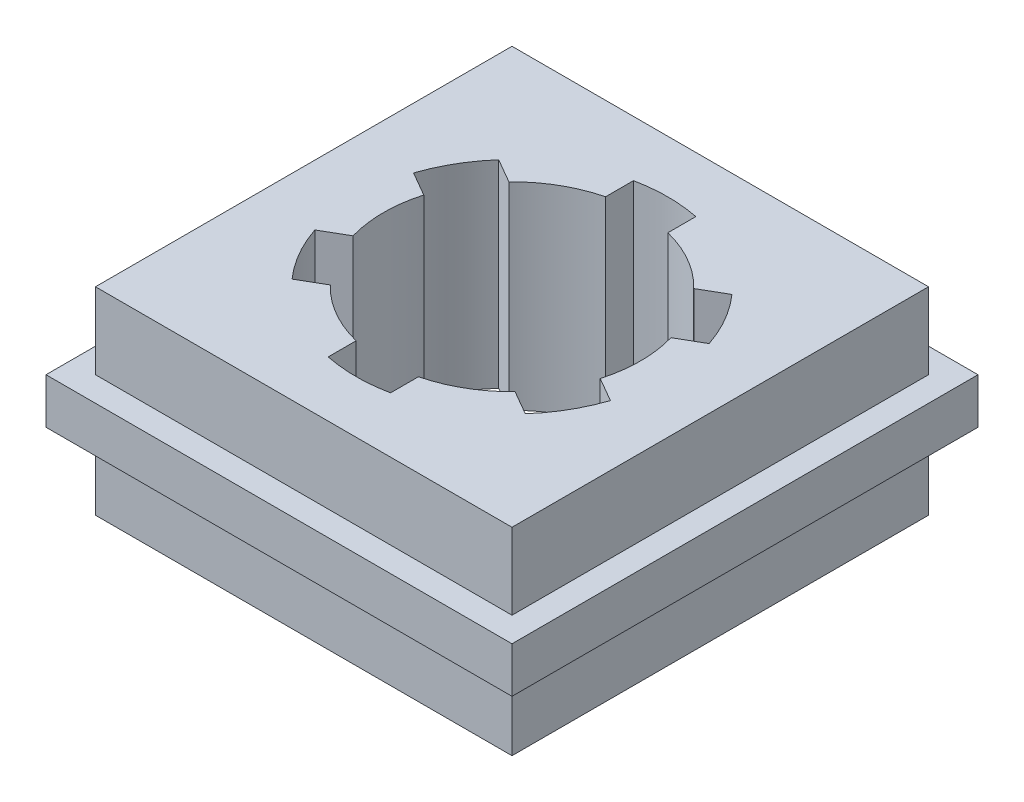
from build123d import *

# Parameters (mm, degrees)
SKETCH1_W           = 26.7335
SKETCH1_H           = 26.7335
BOSS_EXTRUDE1_DEPTH = 6.35
SKETCH2_W           = 29.9085
SKETCH2_H           = 29.9085
BOSS_EXTRUDE2_DEPTH = 1.4605
CUT_EXTRUDE1_DEPTH  = 13.7


with BuildPart() as part:
    # Sketch1 → Boss-Extrude1 (new body, symmetric)
    with BuildSketch(Plane(origin=(0, 0, 0), x_dir=(1, 0, 0), z_dir=(0, 1, 0))):
        Rectangle(SKETCH1_W, SKETCH1_H)
    extrude(amount=BOSS_EXTRUDE1_DEPTH, both=True)

    # Sketch2 → Boss-Extrude2 (add, symmetric)
    with BuildSketch(Plane(origin=(0, 0, 0), x_dir=(1, 0, 0), z_dir=(0, 1, 0))):
        Rectangle(SKETCH2_W, SKETCH2_H)
    extrude(amount=BOSS_EXTRUDE2_DEPTH, both=True)

    # Sketch3 → Cut-Extrude1 (cut, through all)
    with BuildSketch(Plane(origin=(0, 6.35, 0), x_dir=(1, 0, 0), z_dir=(0, 1, 0))):
        with BuildLine():
            Line((-2, 9.797958971), (-2, 8.003905297))
            ThreePointArc((-2, 8.003905297), (-4.125, 7.144709581), (-5.931585317, 5.734003456))
            Line((-5.931585317, 5.734003456), (-7.485281374, 6.631030293))
            ThreePointArc((-7.485281374, 6.631030293), (-8.660254038, 5), (-9.485281374, 3.166928678))
            Line((-9.485281374, 3.166928678), (-7.931585317, 2.269901841))
            ThreePointArc((-7.931585317, 2.269901841), (-8.25, 0), (-7.931585317, -2.269901841))
            Line((-7.931585317, -2.269901841), (-9.485281374, -3.166928678))
            ThreePointArc((-9.485281374, -3.166928678), (-8.660254038, -5), (-7.485281374, -6.631030293))
            Line((-7.485281374, -6.631030293), (-5.931585317, -5.734003456))
            ThreePointArc((-5.931585317, -5.734003456), (-4.125, -7.144709581), (-2, -8.003905297))
            Line((-2, -8.003905297), (-2, -9.797958971))
            ThreePointArc((-2, -9.797958971), (0, -10), (2, -9.797958971))
            Line((2, -9.797958971), (2, -8.003905297))
            ThreePointArc((2, -8.003905297), (4.125, -7.144709581), (5.931585317, -5.734003456))
            Line((5.931585317, -5.734003456), (7.485281374, -6.631030293))
            ThreePointArc((7.485281374, -6.631030293), (8.660254038, -5), (9.485281374, -3.166928678))
            Line((9.485281374, -3.166928678), (7.931585317, -2.269901841))
            ThreePointArc((7.931585317, -2.269901841), (8.25, 0), (7.931585317, 2.269901841))
            Line((7.931585317, 2.269901841), (9.485281374, 3.166928678))
            ThreePointArc((9.485281374, 3.166928678), (8.660254038, 5), (7.485281374, 6.631030293))
            Line((7.485281374, 6.631030293), (5.931585317, 5.734003456))
            ThreePointArc((5.931585317, 5.734003456), (4.125, 7.144709581), (2, 8.003905297))
            Line((2, 8.003905297), (2, 9.797958971))
            ThreePointArc((2, 9.797958971), (0, 10), (-2, 9.797958971))
        make_face()
    extrude(amount=-CUT_EXTRUDE1_DEPTH, mode=Mode.SUBTRACT)


solid = part.part
